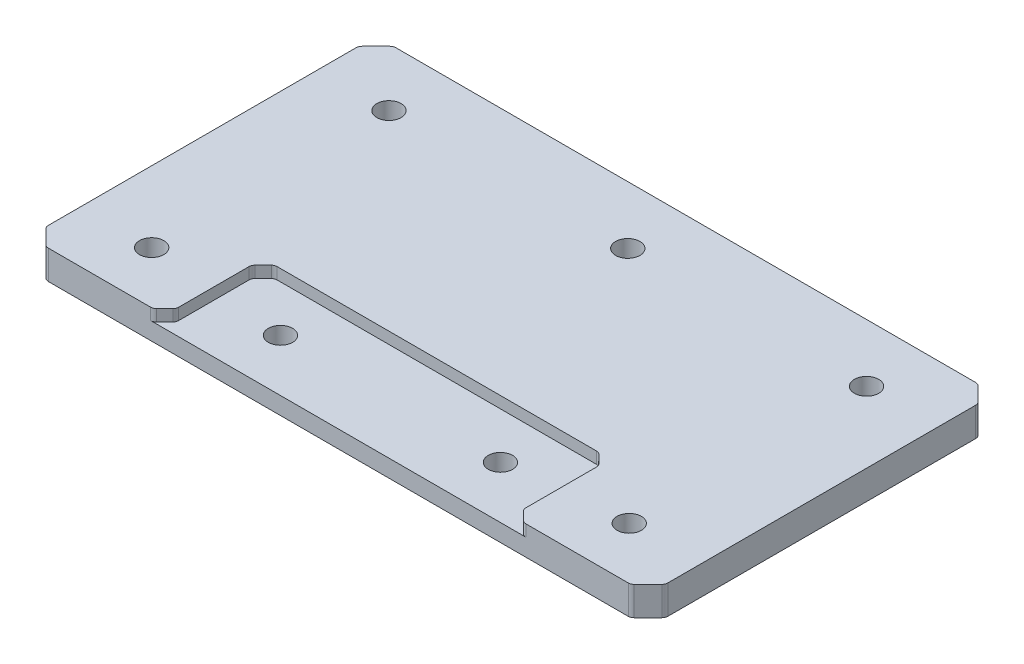
from build123d import *

# Parameters (mm, degrees)
SKETCH1_W                   = 107
SKETCH1_H                   = 60
BOSS_EXTRUDE1_DEPTH         = 5
SKETCH2_W                   = 60
SKETCH2_H                   = 17
CUT_EXTRUDE1_DEPTH          = 2
CHAMFER1_SIZE               = 2
CHAMFER2_SIZE               = 3
FILLET1_R                   = 1
TAP_DRILL_FOR_M5_TAP1_D     = 4.2
TAP_DRILL_FOR_M5_TAP1_DEPTH = 46
TAP_DRILL_FOR_M5_TAP1_TIP   = 1.2618073
TAP_DRILL_FOR_M5_TAP2_D     = 4.2
TAP_DRILL_FOR_M5_TAP2_DEPTH = 46
TAP_DRILL_FOR_M5_TAP2_TIP   = 1.2618073


with BuildPart() as part:
    # Sketch1 → Boss-Extrude1 (new body)
    with BuildSketch(Plane(origin=(0, 0, 0), x_dir=(1, 0, 0), z_dir=(0, 1, 0))):
        Rectangle(SKETCH1_W, SKETCH1_H)
    extrude(amount=BOSS_EXTRUDE1_DEPTH)

    # Sketch2 → Cut-Extrude1 (cut)
    with BuildSketch(Plane(origin=(0, 5, 0), x_dir=(1, 0, 0), z_dir=(0, 1, 0))):
        with Locations((0, -21.5)):
            Rectangle(SKETCH2_W, SKETCH2_H)
    extrude(amount=-CUT_EXTRUDE1_DEPTH, mode=Mode.SUBTRACT)

    # Chamfer1
    chamfer1_edges = [part.edges().sort_by_distance(p)[0] for p in [
        (30, 4, 13),
        (30, 4, 30),
        (-30, 4, 30),
        (-30, 4, 13),
    ]]
    chamfer(chamfer1_edges, length=CHAMFER1_SIZE)

    # Chamfer2
    chamfer2_edges = [part.edges().sort_by_distance(p)[0] for p in [
        (53.5, 2.5, 30),
        (-53.5, 2.5, 30),
        (-53.5, 2.5, -30),
        (53.5, 2.5, -30),
    ]]
    chamfer(chamfer2_edges, length=CHAMFER2_SIZE)

    # Fillet1
    fillet1_edges = [part.edges().sort_by_distance(p)[0] for p in [
        (30, 4, 15),
        (30, 4, 28),
        (-32, 4, 30),
        (32, 4, 30),
        (-28, 4, 13),
        (28, 4, 13),
        (-30, 4, 15),
        (-30, 4, 28),
        (-53.5, 2.5, 27),
        (-53.5, 2.5, -27),
        (50.5, 2.5, -30),
        (-50.5, 2.5, -30),
        (50.5, 2.5, 30),
        (-50.5, 2.5, 30),
        (53.5, 2.5, 27),
        (53.5, 2.5, -27),
    ]]
    fillet(fillet1_edges, radius=FILLET1_R)

    # Tap Drill for M5 Tap1
    with Locations(Plane(origin=(-41.25, 5, 21), x_dir=(0, 0, 1), z_dir=(0, 1, 0))):
        with Locations((0, 0), (-41, 0), (-41, 41.25), (-41, 82.5), (0, 82.5)):
            Hole(TAP_DRILL_FOR_M5_TAP1_D / 2, depth=TAP_DRILL_FOR_M5_TAP1_DEPTH)
            with Locations((0, 0, -(TAP_DRILL_FOR_M5_TAP1_DEPTH + TAP_DRILL_FOR_M5_TAP1_TIP / 2))):  # 118° drill point
                Cone(0, TAP_DRILL_FOR_M5_TAP1_D / 2, TAP_DRILL_FOR_M5_TAP1_TIP, mode=Mode.SUBTRACT)

    # Tap Drill for M5 Tap2
    with Locations(Plane(origin=(-19, 3, 21), x_dir=(0, 0, 1), z_dir=(0, 1, 0))):
        with Locations((0, 0), (0, 38)):
            Hole(TAP_DRILL_FOR_M5_TAP2_D / 2, depth=TAP_DRILL_FOR_M5_TAP2_DEPTH)
            with Locations((0, 0, -(TAP_DRILL_FOR_M5_TAP2_DEPTH + TAP_DRILL_FOR_M5_TAP2_TIP / 2))):  # 118° drill point
                Cone(0, TAP_DRILL_FOR_M5_TAP2_D / 2, TAP_DRILL_FOR_M5_TAP2_TIP, mode=Mode.SUBTRACT)


solid = part.part
